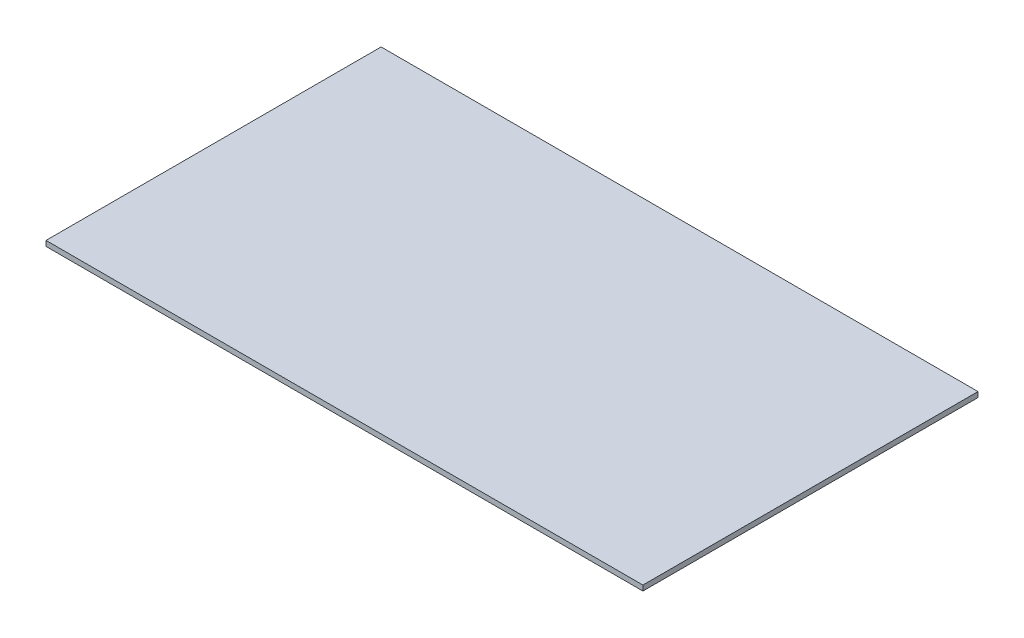
from build123d import *

# Parameters (mm, degrees)
SKETCH1_W           = 542.925
SKETCH1_H           = 304.8
BOSS_EXTRUDE1_DEPTH = 4.7625


with BuildPart() as part:
    # Sketch1 → Boss-Extrude1 (new body)
    with BuildSketch(Plane(origin=(0, 0, 0), x_dir=(1, 0, 0), z_dir=(0, 1, 0))):
        with Locations((271.4625, -152.4)):
            Rectangle(SKETCH1_W, SKETCH1_H)
    extrude(amount=BOSS_EXTRUDE1_DEPTH)


solid = part.part
